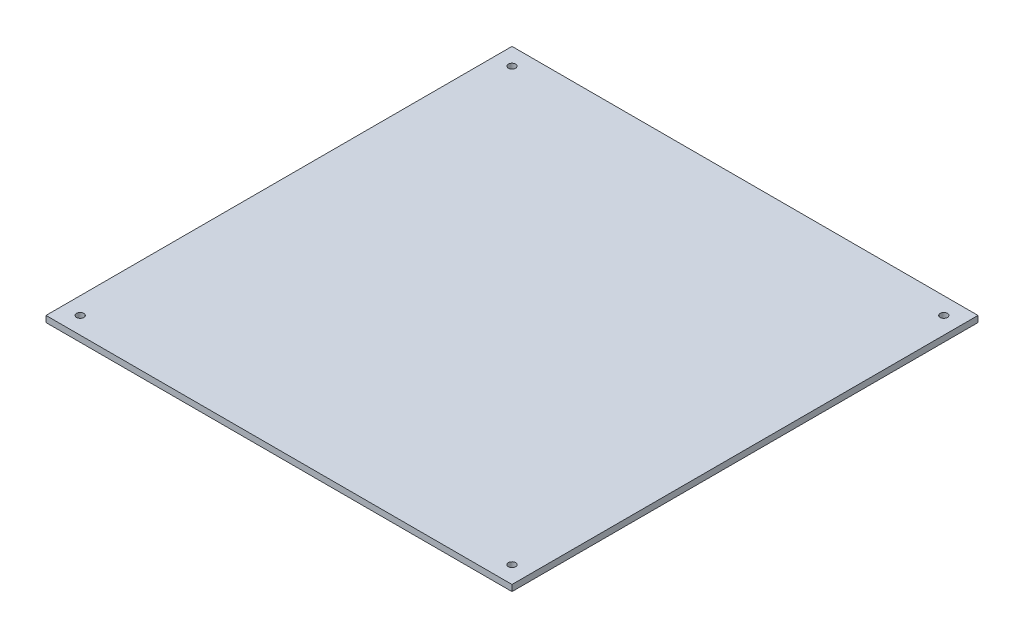
from build123d import *

# Parameters (mm, degrees)
SKETCH1_W           = 225
SKETCH1_H           = 225
BOSS_EXTRUDE1_DEPTH = 3
SKETCH2_R           = 1.75
CUT_EXTRUDE1_DEPTH  = 4


with BuildPart() as part:
    # Sketch1 → Boss-Extrude1 (new body)
    with BuildSketch(Plane(origin=(0, 0, 0), x_dir=(1, 0, 0), z_dir=(0, 1, 0))):
        with Locations((112.5, 112.5)):
            Rectangle(SKETCH1_W, SKETCH1_H)
    extrude(amount=BOSS_EXTRUDE1_DEPTH)

    # Sketch2 → Cut-Extrude1 (cut, through all)
    with BuildSketch(Plane(origin=(0, 3, 0), x_dir=(1, 0, 0), z_dir=(0, 1, 0))):
        with Locations((216.74, 216.74)):
            Circle(SKETCH2_R)
        with Locations((8.26, 216.74)):
            Circle(SKETCH2_R)
        with Locations((216.74, 8.26)):
            Circle(SKETCH2_R)
        with Locations((8.26, 8.26)):
            Circle(SKETCH2_R)
    extrude(amount=-CUT_EXTRUDE1_DEPTH, mode=Mode.SUBTRACT)


solid = part.part
